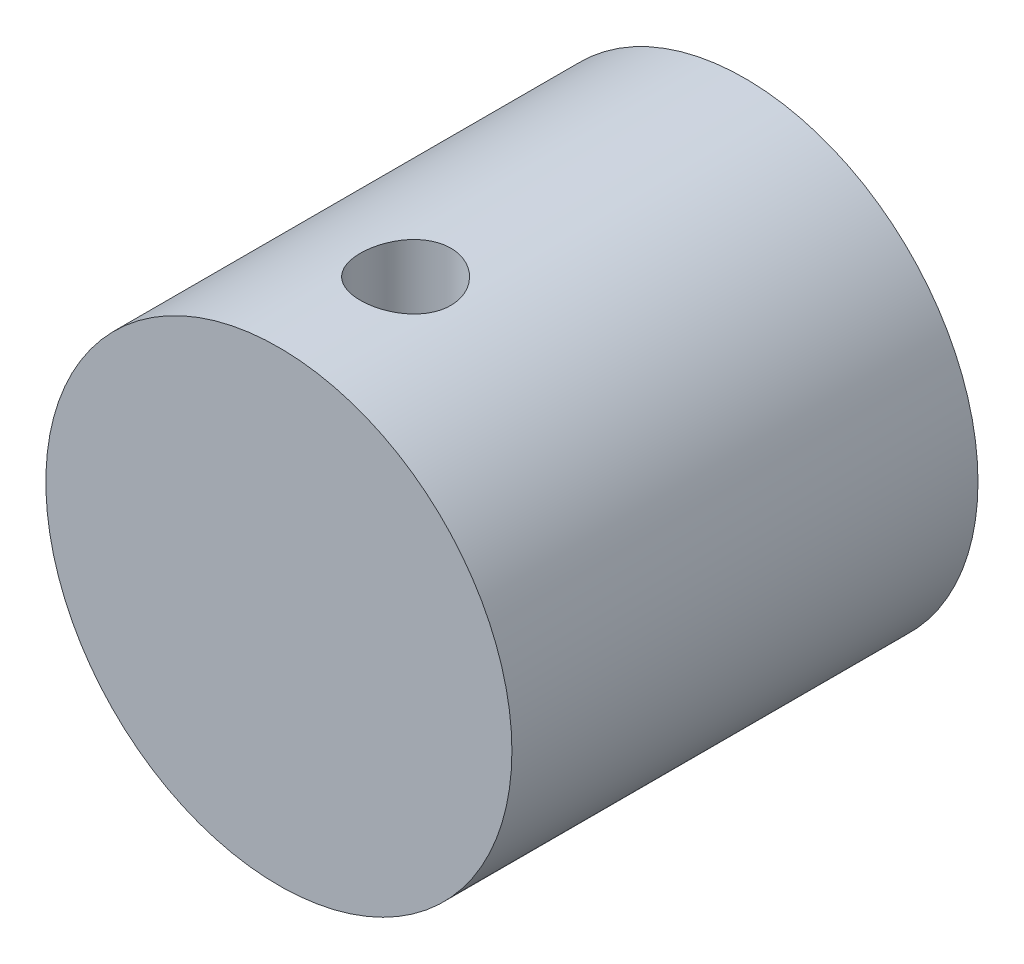
from build123d import *

# Parameters (mm, degrees)
SKETCH1_R               = 5.15
BOSS_EXTRUDE1_DEPTH     = 10.3
CUT_EXTRUDE1_DEPTH      = 10
CUT_EXTRUDE1_DEPTH_BACK = 10
SKETCH2_R               = 1
SKETCH3_W               = 4.05
SKETCH3_H               = 4.05
CUT_EXTRUDE2_DEPTH      = 5


with BuildPart() as part:
    # Sketch1 → Boss-Extrude1 (new body)
    with BuildSketch(Plane.XY):
        Circle(SKETCH1_R)
    extrude(amount=BOSS_EXTRUDE1_DEPTH)

    # Sketch2 → Cut-Extrude1 (cut, two sides: drawn at the far end of the back side and taken through both)
    with BuildSketch(Plane(origin=(0, 0, 0), x_dir=(1, 0, 0), z_dir=(0, 1, 0)).offset(-CUT_EXTRUDE1_DEPTH_BACK)):
        with Locations((0, -7.5)):
            Circle(SKETCH2_R)
    extrude(amount=CUT_EXTRUDE1_DEPTH + CUT_EXTRUDE1_DEPTH_BACK, mode=Mode.SUBTRACT)

    # Sketch3 → Cut-Extrude2 (cut)
    with BuildSketch(Plane(origin=(0, 0, 0), x_dir=(-1, 0, 0), z_dir=(0, 0, -1))):
        Rectangle(SKETCH3_W, SKETCH3_H)
    extrude(amount=-CUT_EXTRUDE2_DEPTH, mode=Mode.SUBTRACT)


solid = part.part
